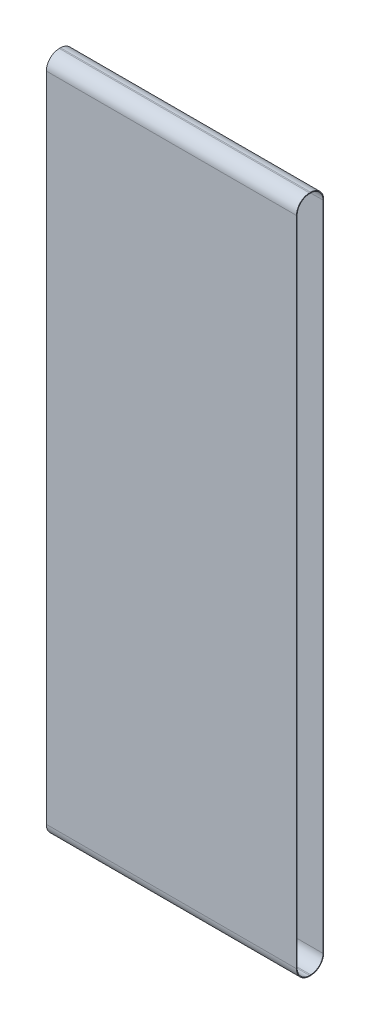
from build123d import *

# Parameters (mm, degrees)
SKETCH1_W           = 482.6
SKETCH1_H           = 52.578
BOSS_EXTRUDE1_DEPTH = 1308.608
FILLET1_R           = 25.1206
CUT_EXTRUDE1_DEPTH  = 483.6


with BuildPart() as part:
    # Sketch1 → Boss-Extrude1 (new body)
    with BuildSketch(Plane(origin=(0, 0, 0), x_dir=(1, 0, 0), z_dir=(0, 1, 0))):
        Rectangle(SKETCH1_W, SKETCH1_H)
    extrude(amount=BOSS_EXTRUDE1_DEPTH)

    # Fillet1
    fillet1_edges = [part.edges().sort_by_distance(p)[0] for p in [
        (0, 1308.608, -26.289),
        (0, 0, -26.289),
        (0, 0, 26.289),
        (0, 1308.608, 26.289),
    ]]
    fillet(fillet1_edges, radius=FILLET1_R)

    # Sketch2 → Cut-Extrude1 (cut, through all)
    with BuildSketch(Plane(origin=(241.3, 0, 0), x_dir=(0, 0, -1), z_dir=(1, 0, 0))):
        with BuildLine():
            Line((24.9428, 25.1206), (24.9428, 1283.4874))
            ThreePointArc((24.9428, 1283.4874), (17.979439459, 1300.298439459), (1.1684, 1307.2618))
            Line((1.1684, 1307.2618), (-1.1684, 1307.2618))
            ThreePointArc((-1.1684, 1307.2618), (-17.979439459, 1300.298439459), (-24.9428, 1283.4874))
            Line((-24.9428, 1283.4874), (-24.9428, 25.1206))
            ThreePointArc((-24.9428, 25.1206), (-17.979439459, 8.309560541), (-1.1684, 1.3462))
            Line((-1.1684, 1.3462), (1.1684, 1.3462))
            ThreePointArc((1.1684, 1.3462), (17.979439459, 8.309560541), (24.9428, 25.1206))
        make_face()
    extrude(amount=-CUT_EXTRUDE1_DEPTH, mode=Mode.SUBTRACT)


solid = part.part
